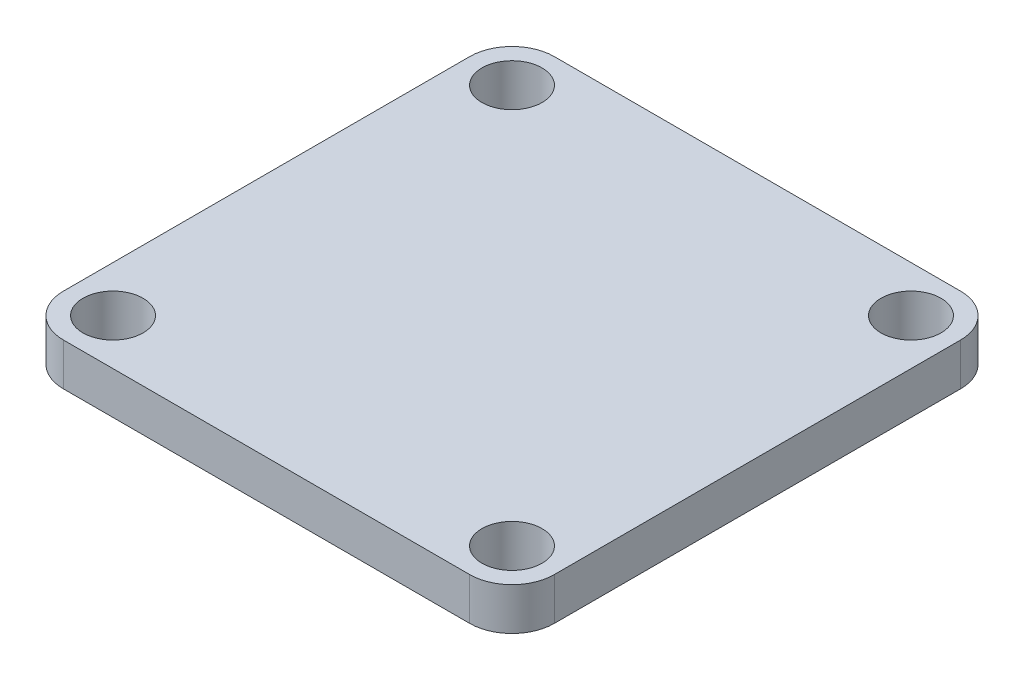
from build123d import *

# Parameters (mm, degrees)
SKETCH1_W           = 58
SKETCH1_H           = 58
SKETCH1_R           = 3.55
BOSS_EXTRUDE1_DEPTH = 5
FILLET1_R           = 5


with BuildPart() as part:
    # Sketch1 → Boss-Extrude1 (new body)
    with BuildSketch(Plane(origin=(0, 0, 0), x_dir=(1, 0, 0), z_dir=(0, 1, 0))):
        Rectangle(SKETCH1_W, SKETCH1_H)
        with Locations((-23.57, 23.57)):
            Circle(SKETCH1_R, mode=Mode.SUBTRACT)
        with Locations((23.57, 23.57)):
            Circle(SKETCH1_R, mode=Mode.SUBTRACT)
        with Locations((23.57, -23.57)):
            Circle(SKETCH1_R, mode=Mode.SUBTRACT)
        with Locations((-23.57, -23.57)):
            Circle(SKETCH1_R, mode=Mode.SUBTRACT)
    extrude(amount=BOSS_EXTRUDE1_DEPTH)

    # Fillet1
    fillet1_edges = [part.edges().sort_by_distance(p)[0] for p in [
        (29, 2.5, 29),
        (-29, 2.5, 29),
        (-29, 2.5, -29),
        (29, 2.5, -29),
    ]]
    fillet(fillet1_edges, radius=FILLET1_R)


solid = part.part
